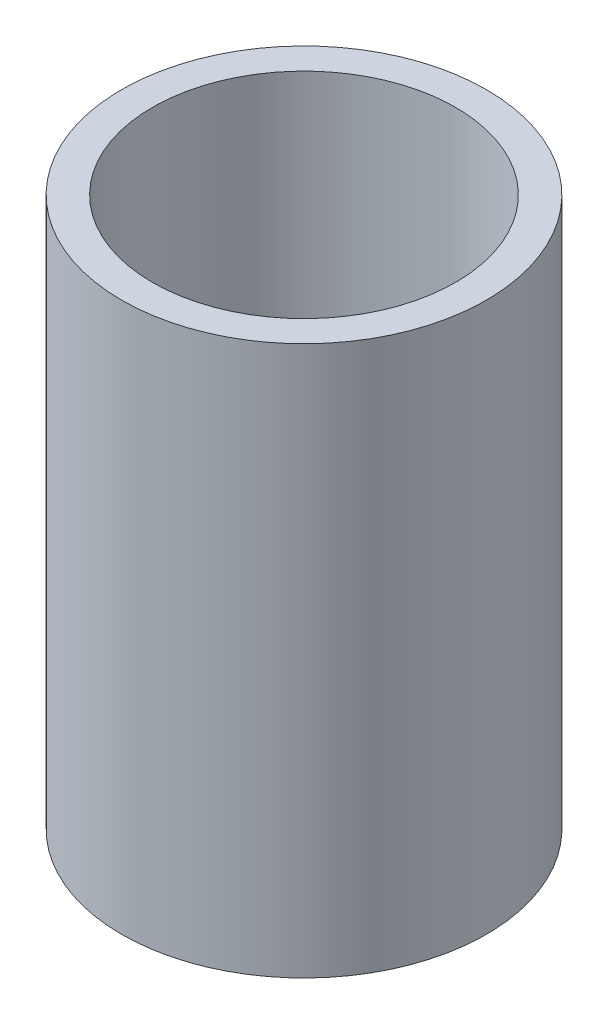
from build123d import *

# Parameters (mm, degrees)
SKETCH1_R           = 21.082
SKETCH1_R_2         = 17.526
BOSS_EXTRUDE1_DEPTH = 63.5


with BuildPart() as part:
    # Sketch1 → Boss-Extrude1 (new body)
    with BuildSketch(Plane(origin=(0, 0, 0), x_dir=(1, 0, 0), z_dir=(0, 1, 0))):
        Circle(SKETCH1_R)
        Circle(SKETCH1_R_2, mode=Mode.SUBTRACT)
    extrude(amount=BOSS_EXTRUDE1_DEPTH)


solid = part.part
